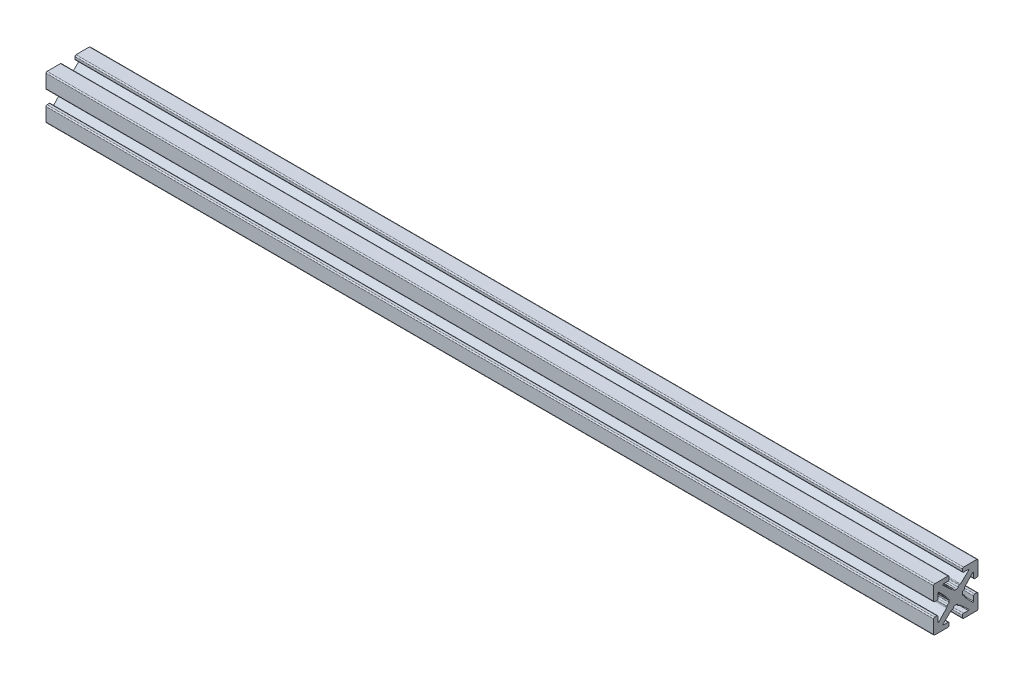
from build123d import *

# Parameters (mm, degrees)
BOSS_EXTRU_1_DEPTH = 200


with BuildPart() as part:
    # Sketch1 → Boss.-Extru.1 (new body)
    with BuildSketch(Plane(origin=(0, 0, 0), x_dir=(0, 0, -1), z_dir=(1, 0, 0))):
        with BuildLine():
            Line((-0.2413, 1.4986), (0.2413, 1.4986))
            ThreePointArc((0.2413, 1.4986), (0.420905122, 1.572994878), (0.4953, 1.7526))
            ThreePointArc((0.4953, 1.7526), (0.569694878, 1.932205122), (0.7493, 2.0066))
            Line((0.7493, 2.0066), (0.889923986, 2.0066))
            ThreePointArc((0.889923986, 2.0066), (0.983516259, 2.024471886), (1.063937899, 2.075572548))
            Line((1.063937899, 2.075572548), (2.890793, 3.793686274))
            ThreePointArc((2.890793, 3.793686274), (2.921850101, 3.932996137), (2.803786044, 4.0132))
            Line((2.803786044, 4.0132), (1.7526, 4.0132))
            ThreePointArc((1.7526, 4.0132), (1.572994878, 4.087594878), (1.4986, 4.2672))
            Line((1.4986, 4.2672), (1.4986, 4.7498))
            ThreePointArc((1.4986, 4.7498), (1.572994878, 4.929405122), (1.7526, 5.0038))
            Line((1.7526, 5.0038), (4.7498, 5.0038))
            ThreePointArc((4.7498, 5.0038), (4.929405122, 4.929405122), (5.0038, 4.7498))
            Line((5.0038, 4.7498), (5.0038, 1.7526))
            ThreePointArc((5.0038, 1.7526), (4.929405122, 1.572994878), (4.7498, 1.4986))
            Line((4.7498, 1.4986), (4.2672, 1.4986))
            ThreePointArc((4.2672, 1.4986), (4.087594878, 1.572994878), (4.0132, 1.7526))
            Line((4.0132, 1.7526), (4.0132, 2.803786044))
            ThreePointArc((4.0132, 2.803786044), (3.932996137, 2.921850101), (3.793686274, 2.890793))
            Line((3.793686274, 2.890793), (2.075572548, 1.063937899))
            ThreePointArc((2.075572548, 1.063937899), (2.024471886, 0.983516259), (2.0066, 0.889923986))
            Line((2.0066, 0.889923986), (2.0066, 0.7493))
            ThreePointArc((2.0066, 0.7493), (1.932205122, 0.569694878), (1.7526, 0.4953))
            ThreePointArc((1.7526, 0.4953), (1.572994878, 0.420905122), (1.4986, 0.2413))
            Line((1.4986, 0.2413), (1.4986, -0.2413))
            ThreePointArc((1.4986, -0.2413), (1.572994878, -0.420905122), (1.7526, -0.4953))
            ThreePointArc((1.7526, -0.4953), (1.932205122, -0.569694878), (2.0066, -0.7493))
            Line((2.0066, -0.7493), (2.0066, -0.889923986))
            ThreePointArc((2.0066, -0.889923986), (2.024471886, -0.983516259), (2.075572548, -1.063937899))
            Line((2.075572548, -1.063937899), (3.793686274, -2.890793))
            ThreePointArc((3.793686274, -2.890793), (3.932996137, -2.921850101), (4.0132, -2.803786044))
            Line((4.0132, -2.803786044), (4.0132, -1.7526))
            ThreePointArc((4.0132, -1.7526), (4.087594878, -1.572994878), (4.2672, -1.4986))
            Line((4.2672, -1.4986), (4.7498, -1.4986))
            ThreePointArc((4.7498, -1.4986), (4.929405122, -1.572994878), (5.0038, -1.7526))
            Line((5.0038, -1.7526), (5.0038, -4.7498))
            ThreePointArc((5.0038, -4.7498), (4.929405122, -4.929405122), (4.7498, -5.0038))
            Line((4.7498, -5.0038), (1.7526, -5.0038))
            ThreePointArc((1.7526, -5.0038), (1.572994878, -4.929405122), (1.4986, -4.7498))
            Line((1.4986, -4.7498), (1.4986, -4.2672))
            ThreePointArc((1.4986, -4.2672), (1.572994878, -4.087594878), (1.7526, -4.0132))
            Line((1.7526, -4.0132), (2.803786044, -4.0132))
            ThreePointArc((2.803786044, -4.0132), (2.921850101, -3.932996137), (2.890793, -3.793686274))
            Line((2.890793, -3.793686274), (1.063937899, -2.075572548))
            ThreePointArc((1.063937899, -2.075572548), (0.983516259, -2.024471886), (0.889923986, -2.0066))
            Line((0.889923986, -2.0066), (0.7493, -2.0066))
            ThreePointArc((0.7493, -2.0066), (0.569694878, -1.932205122), (0.4953, -1.7526))
            ThreePointArc((0.4953, -1.7526), (0.420905122, -1.572994878), (0.2413, -1.4986))
            Line((0.2413, -1.4986), (-0.2413, -1.4986))
            ThreePointArc((-0.2413, -1.4986), (-0.420905122, -1.572994878), (-0.4953, -1.7526))
            ThreePointArc((-0.4953, -1.7526), (-0.569694878, -1.932205122), (-0.7493, -2.0066))
            Line((-0.7493, -2.0066), (-0.889923986, -2.0066))
            ThreePointArc((-0.889923986, -2.0066), (-0.983516259, -2.024471886), (-1.063937899, -2.075572548))
            Line((-1.063937899, -2.075572548), (-2.890793, -3.793686274))
            ThreePointArc((-2.890793, -3.793686274), (-2.921850101, -3.932996137), (-2.803786044, -4.0132))
            Line((-2.803786044, -4.0132), (-1.7526, -4.0132))
            ThreePointArc((-1.7526, -4.0132), (-1.572994878, -4.087594878), (-1.4986, -4.2672))
            Line((-1.4986, -4.2672), (-1.4986, -4.7498))
            ThreePointArc((-1.4986, -4.7498), (-1.572994878, -4.929405122), (-1.7526, -5.0038))
            Line((-1.7526, -5.0038), (-4.7498, -5.0038))
            ThreePointArc((-4.7498, -5.0038), (-4.929405122, -4.929405122), (-5.0038, -4.7498))
            Line((-5.0038, -4.7498), (-5.0038, -1.7526))
            ThreePointArc((-5.0038, -1.7526), (-4.929405122, -1.572994878), (-4.7498, -1.4986))
            Line((-4.7498, -1.4986), (-4.2672, -1.4986))
            ThreePointArc((-4.2672, -1.4986), (-4.087594878, -1.572994878), (-4.0132, -1.7526))
            Line((-4.0132, -1.7526), (-4.0132, -2.803786044))
            ThreePointArc((-4.0132, -2.803786044), (-3.932996137, -2.921850101), (-3.793686274, -2.890793))
            Line((-3.793686274, -2.890793), (-2.075572548, -1.063937899))
            ThreePointArc((-2.075572548, -1.063937899), (-2.024471886, -0.983516259), (-2.0066, -0.889923986))
            Line((-2.0066, -0.889923986), (-2.0066, -0.7493))
            ThreePointArc((-2.0066, -0.7493), (-1.932205122, -0.569694878), (-1.7526, -0.4953))
            ThreePointArc((-1.7526, -0.4953), (-1.572994878, -0.420905122), (-1.4986, -0.2413))
            Line((-1.4986, -0.2413), (-1.4986, 0.2413))
            ThreePointArc((-1.4986, 0.2413), (-1.572994878, 0.420905122), (-1.7526, 0.4953))
            ThreePointArc((-1.7526, 0.4953), (-1.932205122, 0.569694878), (-2.0066, 0.7493))
            Line((-2.0066, 0.7493), (-2.0066, 0.889923986))
            ThreePointArc((-2.0066, 0.889923986), (-2.024471886, 0.983516259), (-2.075572548, 1.063937899))
            Line((-2.075572548, 1.063937899), (-3.793686274, 2.890793))
            ThreePointArc((-3.793686274, 2.890793), (-3.932996137, 2.921850101), (-4.0132, 2.803786044))
            Line((-4.0132, 2.803786044), (-4.0132, 1.7526))
            ThreePointArc((-4.0132, 1.7526), (-4.087594878, 1.572994878), (-4.2672, 1.4986))
            Line((-4.2672, 1.4986), (-4.7498, 1.4986))
            ThreePointArc((-4.7498, 1.4986), (-4.929405122, 1.572994878), (-5.0038, 1.7526))
            Line((-5.0038, 1.7526), (-5.0038, 4.7498))
            ThreePointArc((-5.0038, 4.7498), (-4.929405122, 4.929405122), (-4.7498, 5.0038))
            Line((-4.7498, 5.0038), (-1.7526, 5.0038))
            ThreePointArc((-1.7526, 5.0038), (-1.572994878, 4.929405122), (-1.4986, 4.7498))
            Line((-1.4986, 4.7498), (-1.4986, 4.2672))
            ThreePointArc((-1.4986, 4.2672), (-1.572994878, 4.087594878), (-1.7526, 4.0132))
            Line((-1.7526, 4.0132), (-2.803786044, 4.0132))
            ThreePointArc((-2.803786044, 4.0132), (-2.921850101, 3.932996137), (-2.890793, 3.793686274))
            Line((-2.890793, 3.793686274), (-1.063937899, 2.075572548))
            ThreePointArc((-1.063937899, 2.075572548), (-0.983516259, 2.024471886), (-0.889923986, 2.0066))
            Line((-0.889923986, 2.0066), (-0.7493, 2.0066))
            ThreePointArc((-0.7493, 2.0066), (-0.569694878, 1.932205122), (-0.4953, 1.7526))
            ThreePointArc((-0.4953, 1.7526), (-0.420905122, 1.572994878), (-0.2413, 1.4986))
        make_face()
    extrude(amount=BOSS_EXTRU_1_DEPTH)


solid = part.part
